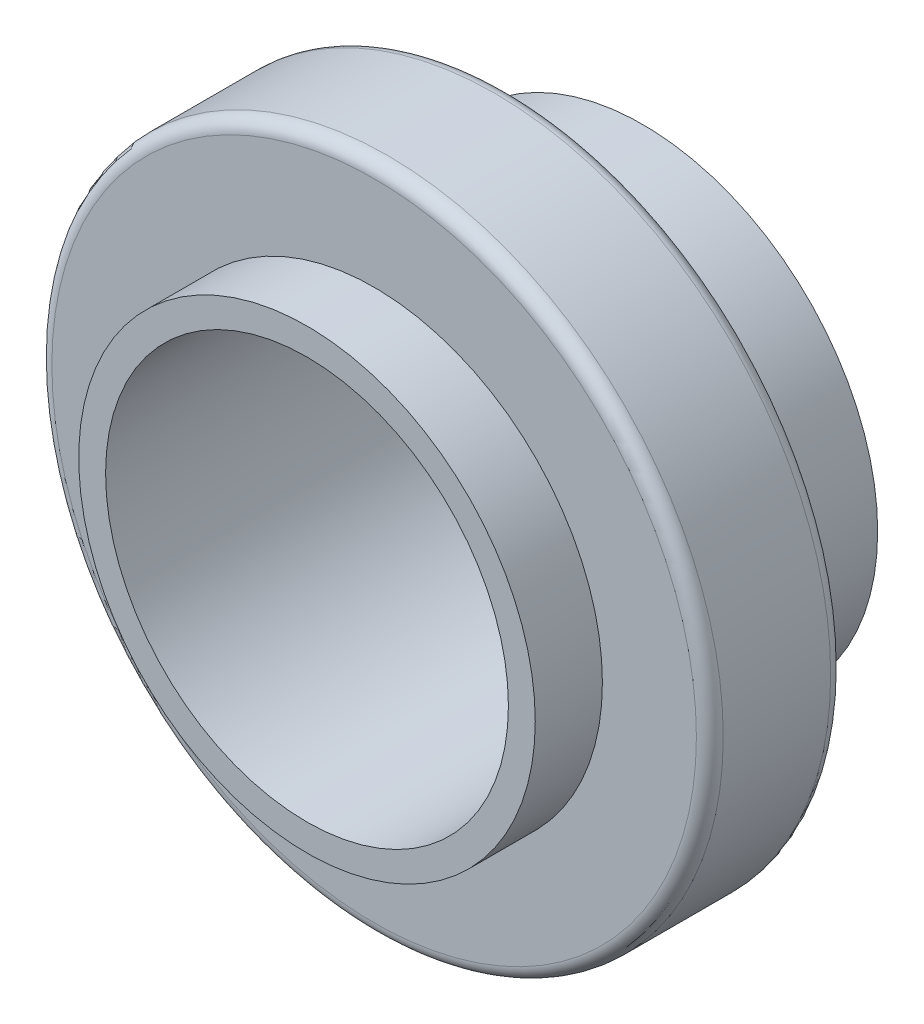
from build123d import *

# Parameters (mm, degrees)
SKETCH1_R               = 17.5
BOSS_EXTRUDE1_DEPTH     = 10
SKETCH2_R               = 25
BOSS_EXTRUDE2_DEPTH     = 10
SKETCH3_R               = 17
BOSS_EXTRUDE3_DEPTH     = 5
SKETCH4_R               = 15
CUT_EXTRUDE1_DEPTH      = 1
CUT_EXTRUDE1_DEPTH_BACK = 26
FILLET1_R               = 1


with BuildPart() as part:
    # Sketch1 → Boss-Extrude1 (new body)
    with BuildSketch(Plane.XY):
        Circle(SKETCH1_R)
    extrude(amount=BOSS_EXTRUDE1_DEPTH)

    # Sketch2 → Boss-Extrude2 (add)
    with BuildSketch(Plane.XY.offset(10)):
        Circle(SKETCH2_R)
    extrude(amount=BOSS_EXTRUDE2_DEPTH)

    # Sketch3 → Boss-Extrude3 (add)
    with BuildSketch(Plane.XY.offset(20)):
        Circle(SKETCH3_R)
    extrude(amount=BOSS_EXTRUDE3_DEPTH)

    # Sketch4 → Cut-Extrude1 (cut, two sides)
    with BuildSketch(Plane.XY.offset(25)) as cut_extrude1_sk:
        Circle(SKETCH4_R)
    extrude(amount=CUT_EXTRUDE1_DEPTH, mode=Mode.SUBTRACT)
    extrude(cut_extrude1_sk.sketch, amount=-CUT_EXTRUDE1_DEPTH_BACK, mode=Mode.SUBTRACT)

    # Fillet1
    fillet1_edges = [part.edges().sort_by_distance(p)[0] for p in [
        (-25, 0, 10),
        (-25, 0, 20),
    ]]
    fillet(fillet1_edges, radius=FILLET1_R)


solid = part.part
